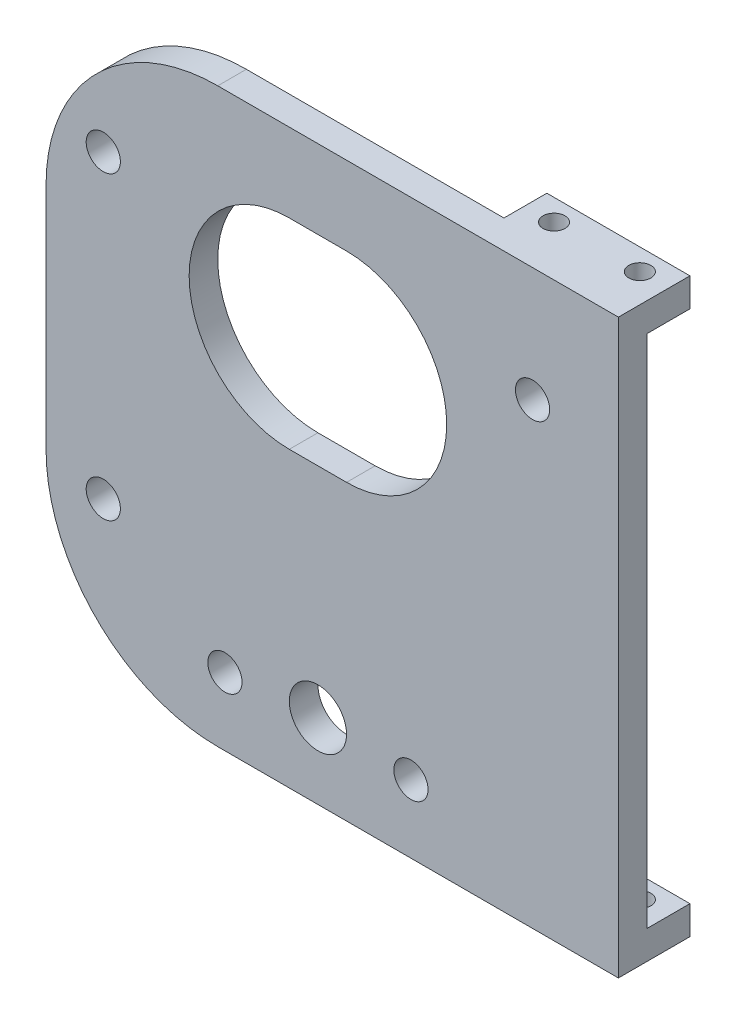
from build123d import *

# Parameters (mm, degrees)
SKETCH1_W                 = 63.5
SKETCH1_H                 = 63.5
BOSS_EXTRUDE1_DEPTH       = 3.175
BOSS_EXTRUDE2_DEPTH       = 4.7625
F_2_CLEARANCE_HOLE1_D     = 2.4384
F_2_CLEARANCE_HOLE1_DEPTH = 3.175
FILLET1_R                 = 19.05
SKETCH5_W                 = 15.875
SKETCH5_H                 = 3.175
BOSS_EXTRUDE3_DEPTH       = 4.7625
F_2_CLEARANCE_HOLE2_D     = 2.4384
F_2_CLEARANCE_HOLE2_DEPTH = 3.175
BOSS_EXTRUDE4_START       = -3.175
SKETCH8_R                 = 3.175
BOSS_EXTRUDE4_DEPTH       = 3.175
F_6_CLEARANCE_HOLE1_D     = 3.7973
CUT_EXTRUDE1_REACH        = 9.938
SKETCH11_R                = 3.175


with BuildPart() as part:
    # Sketch1 → Boss-Extrude1 (new body)
    with BuildSketch(Plane.XY):
        Rectangle(SKETCH1_W, SKETCH1_H)
    extrude(amount=BOSS_EXTRUDE1_DEPTH)

    # Sketch2 → Boss-Extrude2 (add)
    with BuildSketch(Plane(origin=(0, 0, 0), x_dir=(-1, 0, 0), z_dir=(0, 0, -1))):
        Polygon((-25.4, -31.75), (-15.875, -31.75), (-15.875, -28.575), (-25.4, -28.575), (-31.75, -28.575), (-31.75, -31.75), align=None)
    extrude(amount=BOSS_EXTRUDE2_DEPTH)

    # #2 Clearance Hole1
    with Locations(Plane(origin=(0, -28.575, 0), x_dir=(1, 0, 0), z_dir=(0, 1, 0))):
        with Locations((28.575, 2.38125), (19.05, 2.38125)):
            Hole(F_2_CLEARANCE_HOLE1_D / 2, depth=F_2_CLEARANCE_HOLE1_DEPTH)

    # Fillet1
    fillet1_edges = [part.edges().sort_by_distance(p)[0] for p in [
        (-31.75, -31.75, 1.5875),
        (-31.75, 31.75, 1.5875),
    ]]
    fillet(fillet1_edges, radius=FILLET1_R)

    # Sketch5 → Boss-Extrude3 (add)
    with BuildSketch(Plane(origin=(0, 0, 0), x_dir=(-1, 0, 0), z_dir=(0, 0, -1))):
        with Locations((-23.8125, 30.1625)):
            Rectangle(SKETCH5_W, SKETCH5_H)
    extrude(amount=BOSS_EXTRUDE3_DEPTH)

    # #2 Clearance Hole2
    with Locations(Plane(origin=(0, 28.575, 0), x_dir=(-1, 0, 0), z_dir=(0, -1, 0))):
        with Locations((-19.05, 2.38125), (-28.575, 2.38125)):
            Hole(F_2_CLEARANCE_HOLE2_D / 2, depth=F_2_CLEARANCE_HOLE2_DEPTH)

    # Sketch8 → Boss-Extrude4 (add)
    with BuildSketch(Plane.XY.offset(3.175).offset(BOSS_EXTRUDE4_START)):
        with Locations((-25.4, 19.05)):
            Circle(SKETCH8_R)
        with Locations((-25.4, -14.2875)):
            Circle(SKETCH8_R)
        with Locations((22.225, 19.05)):
            Circle(SKETCH8_R)
        with Locations((8.73125, -24.209375)):
            Circle(SKETCH8_R)
        with Locations((-11.90625, -24.209375)):
            Circle(SKETCH8_R)
    extrude(amount=-BOSS_EXTRUDE4_DEPTH)

    # #6 Clearance Hole1 (through all)
    with Locations(Plane(origin=(0, 0, -3.175), x_dir=(-1, 0, 0), z_dir=(0, 0, -1))):
        with Locations((-22.225, 19.05), (25.4, 19.05), (25.4, -14.2875), (11.90625, -24.209375), (-8.73125, -24.209375)):
            Hole(F_6_CLEARANCE_HOLE1_D / 2)

    # Sketch11 → Cut-Extrude1 (cut, up to next)
    with BuildSketch(Plane.XY.offset(3.175), mode=Mode.PRIVATE) as cut_extrude1_sk1:
        with Locations((-1.5875, -23.415625)):
            Circle(SKETCH11_R)
    cut_extrude1_tool1 = extrude(cut_extrude1_sk1.sketch, amount=-CUT_EXTRUDE1_REACH, mode=Mode.PRIVATE) & part.part
    add(cut_extrude1_tool1.solids().sort_by_distance((-1.5875, -23.415625, 3.175))[0], mode=Mode.SUBTRACT)
    # Sketch11 → Cut-Extrude1 (cut, up to next)
    with BuildSketch(Plane.XY.offset(3.175), mode=Mode.PRIVATE) as cut_extrude1_sk2:
        with BuildLine():
            Line((-4.7625, 23.01875), (1.5875, 23.01875))
            ThreePointArc((1.5875, 23.01875), (12.7, 11.90625), (1.5875, 0.79375))
            Line((1.5875, 0.79375), (-4.7625, 0.79375))
            ThreePointArc((-4.7625, 0.79375), (-15.875, 11.90625), (-4.7625, 23.01875))
        make_face()
    cut_extrude1_tool2 = extrude(cut_extrude1_sk2.sketch, amount=-CUT_EXTRUDE1_REACH, mode=Mode.PRIVATE) & part.part
    add(cut_extrude1_tool2.solids().sort_by_distance((-1.5875, 11.90625, 3.175))[0], mode=Mode.SUBTRACT)


solid = part.part
